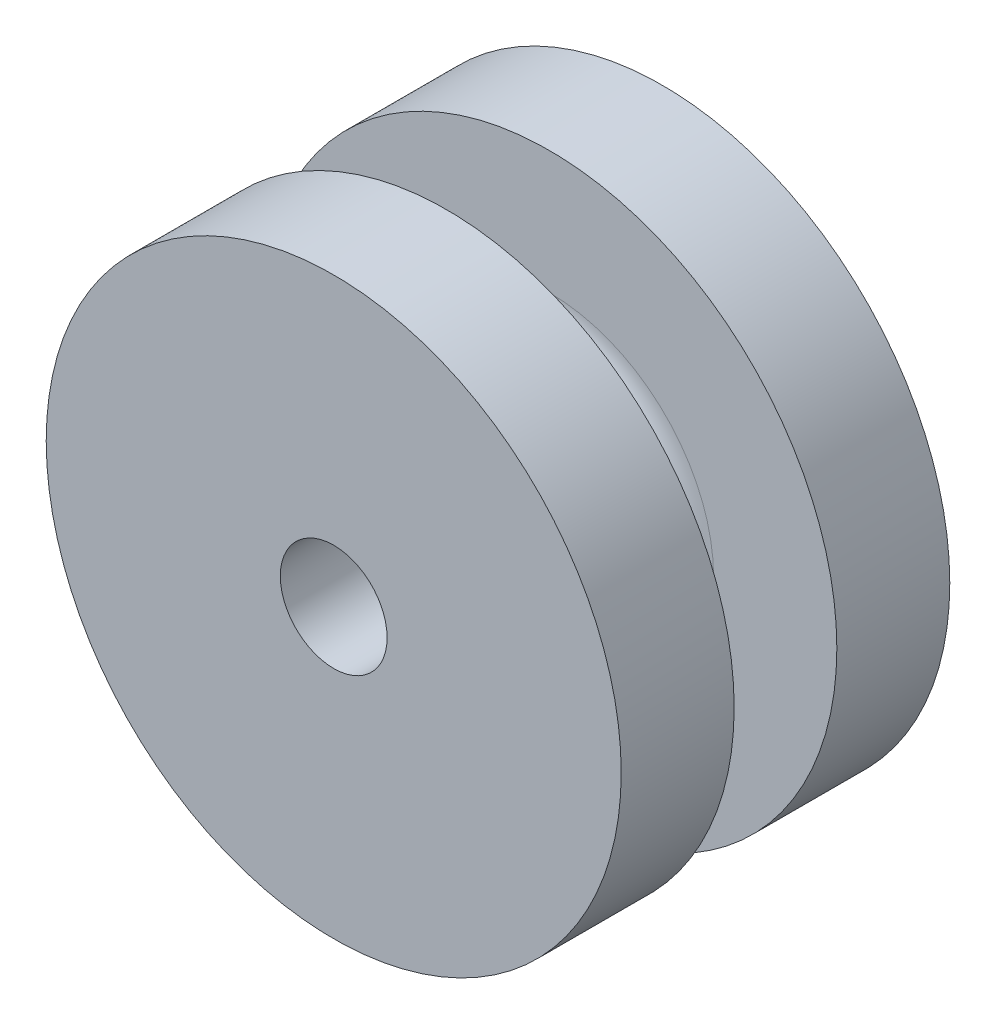
from build123d import *

# Parameters (mm, degrees)
ESQUISSE1_R                  = 7
BOSS_EXTRU_1_DEPTH           = 8
ESQUISSE2_R                  = 7
ESQUISSE2_R_2                = 3
ENL_V_MAT_EXTRU_2_DEPTH      = 1.25
ENL_V_MAT_EXTRU_2_DEPTH_BACK = 1.25
CONG_1_R                     = 1
ENL_V_MAT_EXTRU_3_REACH      = 10
ESQUISSE3_R                  = 1.3


with BuildPart() as part:
    # Esquisse1 → Boss.-Extru.1 (new body)
    with BuildSketch(Plane.XY):
        Circle(ESQUISSE1_R)
    extrude(amount=BOSS_EXTRU_1_DEPTH)

    # Esquisse2 → Enlèv. mat.-Extru.2 (cut, two sides)
    with BuildSketch(Plane(origin=(0, 0, 4), x_dir=(-1, 0, 0), z_dir=(0, 0, -1))) as enl_v_mat_extru_2_sk:
        Circle(ESQUISSE2_R)
        Circle(ESQUISSE2_R_2, mode=Mode.SUBTRACT)
    extrude(amount=ENL_V_MAT_EXTRU_2_DEPTH, mode=Mode.SUBTRACT)
    extrude(enl_v_mat_extru_2_sk.sketch, amount=-ENL_V_MAT_EXTRU_2_DEPTH_BACK, mode=Mode.SUBTRACT)

    # Congé1
    cong_1_edges = [part.edges().sort_by_distance(p)[0] for p in [
        (3, 0, 2.75),
        (3, 0, 5.25),
    ]]
    fillet(cong_1_edges, radius=CONG_1_R)

    # Esquisse3 → Enlèv. mat.-Extru.3 (cut, up to next)
    with BuildSketch(Plane(origin=(0, 0, 0), x_dir=(-1, 0, 0), z_dir=(0, 0, -1)), mode=Mode.PRIVATE) as enl_v_mat_extru_3_sk1:
        Circle(ESQUISSE3_R)
    enl_v_mat_extru_3_tool1 = extrude(enl_v_mat_extru_3_sk1.sketch, amount=-ENL_V_MAT_EXTRU_3_REACH, mode=Mode.PRIVATE) & part.part
    add(enl_v_mat_extru_3_tool1.solids().sort_by_distance((0, 0, 0))[0], mode=Mode.SUBTRACT)


solid = part.part
